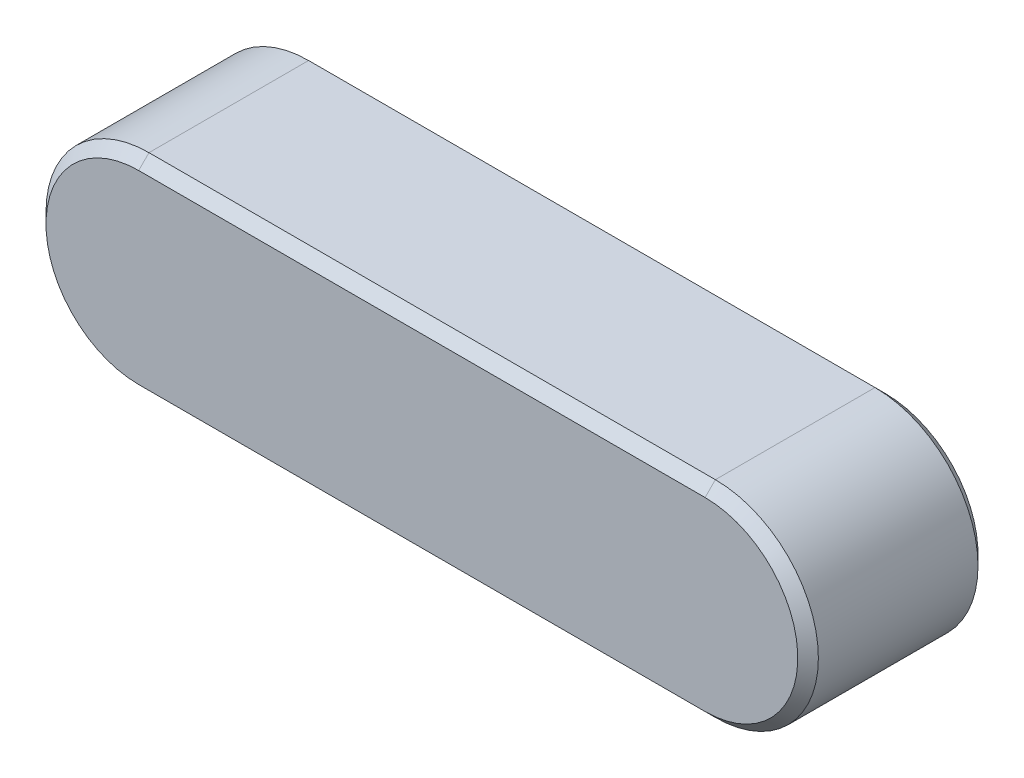
from build123d import *

# Parameters (mm, degrees)
BASEKEY_DEPTH = 3.5
CHAMFER1_SIZE = 0.4


with BuildPart() as part:
    # Sketch1 → BaseKey (new body, symmetric)
    with BuildSketch(Plane.XY):
        with BuildLine():
            Line((-22, 4), (0, 4))
            ThreePointArc((0, 4), (4, 0), (0, -4))
            Line((0, -4), (-22, -4))
            ThreePointArc((-22, -4), (-26, 0), (-22, 4))
        make_face()
    extrude(amount=BASEKEY_DEPTH, both=True)

    # Chamfer1
    chamfer1_edges = [part.edges().sort_by_distance(p)[0] for p in [
        (4, 0, 3.5),
        (-11, 4, 3.5),
        (-26, 0, 3.5),
        (-11, 4, -3.5),
        (4, 0, -3.5),
        (-11, -4, -3.5),
        (-26, 0, -3.5),
        (-11, -4, 3.5),
    ]]
    chamfer(chamfer1_edges, length=CHAMFER1_SIZE)


solid = part.part
